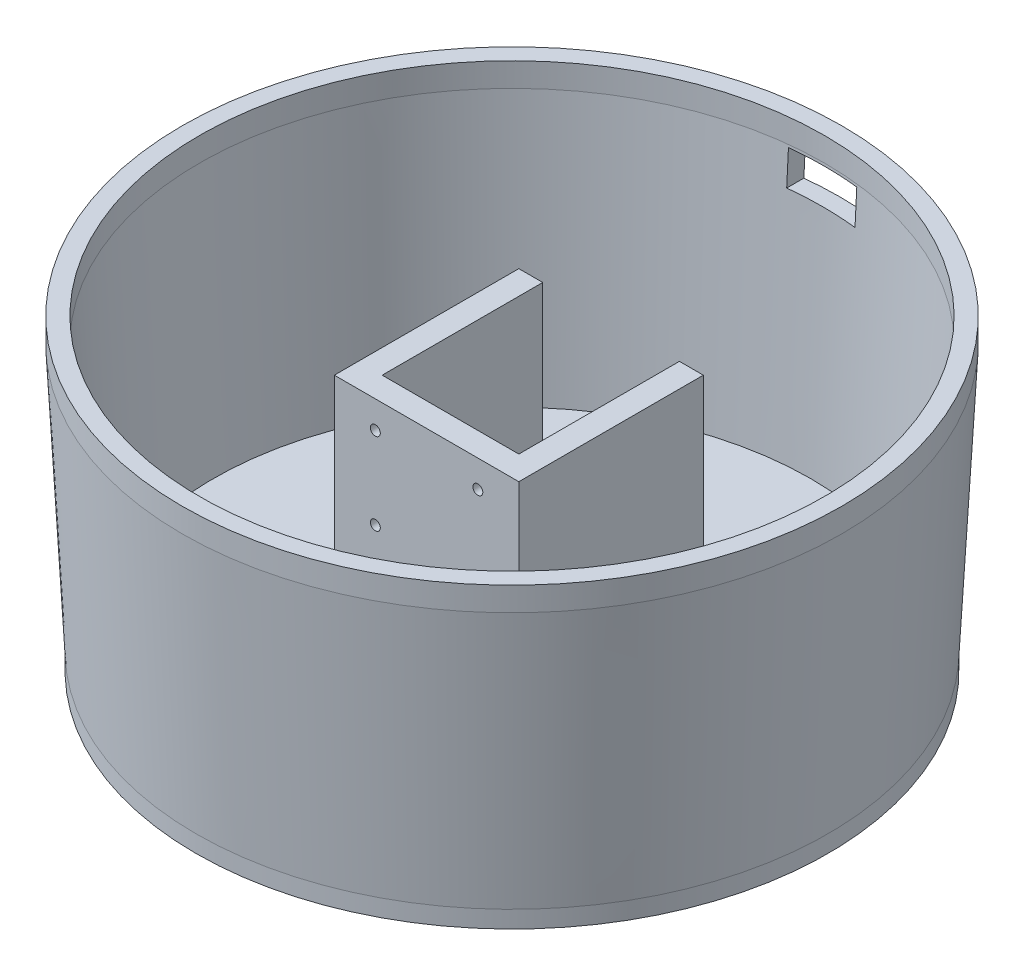
from build123d import *

# Parameters (mm, degrees)
SKETCH_1_R          = 92.5
SKETCH_1_R_2        = 15.2
EXTRUDE_1_DEPTH     = 5
SKETCH_8_W          = 5
SKETCH_8_H          = 7
EXTRUDE_2_DEPTH     = 85
SKETCH_11_R         = 1.45
CUT_EXTRUDE_1_DEPTH = 85
SKETCH_12_W         = 54
SKETCH_12_H         = 16
CUT_EXTRUDE_2_DEPTH = 85
SKETCH_14_W         = 20
SKETCH_14_H         = 10
CUT_EXTRUDE_3_DEPTH = 100


with BuildPart() as part:
    # 스케치1 → 보스-돌출1 (new body)
    with BuildSketch(Plane(origin=(0, 0, 0), x_dir=(1, 0, 0), z_dir=(0, 1, 0))):
        Circle(SKETCH_1_R)
        Circle(SKETCH_1_R_2, mode=Mode.SUBTRACT)
    extrude(amount=EXTRUDE_1_DEPTH)

    # 스케치5 → 회전1 (revolve)
    with BuildSketch(Plane.XY):
        Polygon((-92.5, 5), (-96.5, 83), (-91.5, 83), (-87.5, 5), align=None)
    revolve(axis=Axis((0, 0, 0), (0, 1, 0)))

    # 스케치8 → 회전3 (revolve)
    with BuildSketch(Plane.XY):
        with Locations((-94, 86.5)):
            Rectangle(SKETCH_8_W, SKETCH_8_H)
    revolve(axis=Axis((0, 0, 0), (0, 1, 0)))

    # 스케치9 → 보스-돌출2 (add)
    with BuildSketch(Plane(origin=(0, 5, 0), x_dir=(1, 0, 0), z_dir=(0, 1, 0))):
        Polygon((-20, -25), (20, -25), (27, -25), (27, 29), (20, 29), (20, -18), (-20, -18), (-20, 29), (-27, 29), (-27, -25), align=None)
    extrude(amount=EXTRUDE_2_DEPTH)

    # 스케치11 → 컷-돌출1 (cut)
    with BuildSketch(Plane.XY.offset(25)):
        with Locations((15, 42)):
            Circle(SKETCH_11_R)
        with Locations((-15, 42)):
            Circle(SKETCH_11_R)
        with Locations((-15, 66)):
            Circle(SKETCH_11_R)
        with Locations((15, 66)):
            Circle(SKETCH_11_R)
    extrude(amount=-CUT_EXTRUDE_1_DEPTH, mode=Mode.SUBTRACT)

    # 스케치12 → 컷-돌출2 (cut)
    with BuildSketch(Plane.XY.offset(25)):
        with Locations((0, 82)):
            Rectangle(SKETCH_12_W, SKETCH_12_H)
    extrude(amount=-CUT_EXTRUDE_2_DEPTH, mode=Mode.SUBTRACT)

    # 스케치14 → 컷-돌출3 (cut)
    with BuildSketch(Plane.XY):
        with Locations((0, 77.228887743)):
            Rectangle(SKETCH_14_W, SKETCH_14_H)
    extrude(amount=-CUT_EXTRUDE_3_DEPTH, mode=Mode.SUBTRACT)


solid = part.part
